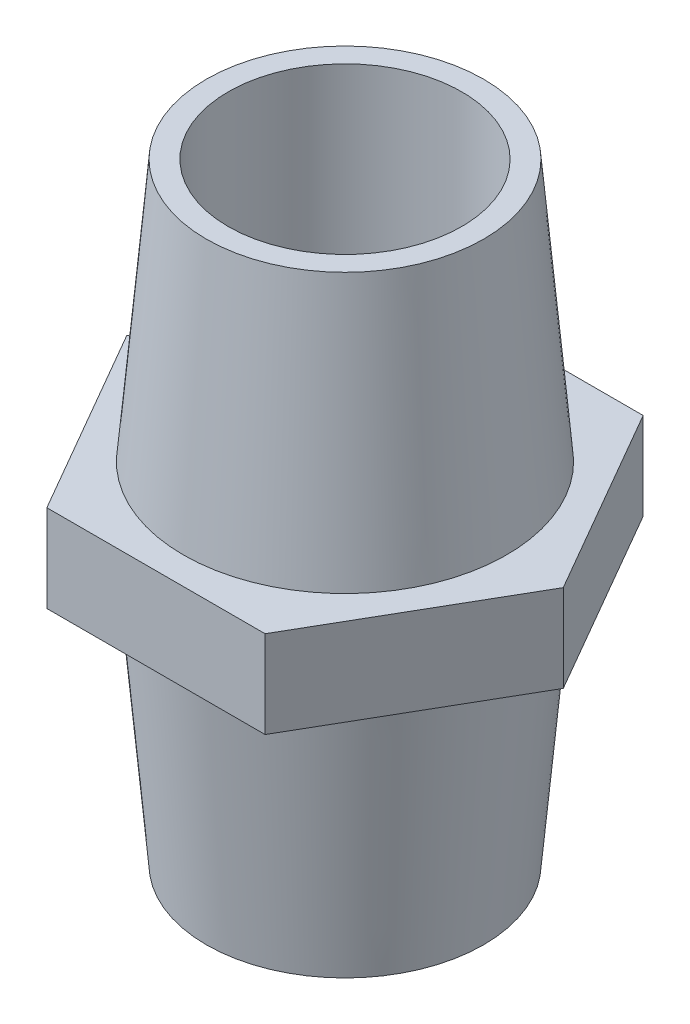
from build123d import *

# Parameters (mm, degrees)
CROQUIS2_OUTSIDE_W    = 43.94
CROQUIS2_OUTSIDE_H    = 43.94
CORTAR_EXTRUIR1_DEPTH = 25


with BuildPart() as part:
    # Croquis1 → Revolución1 (revolve)
    with BuildSketch(Plane.XY):
        Polygon((8.025, 24), (8.025, -18), (9.525, -18), (11.11, 0), (15, 0), (15, 6), (11.11, 6), (9.525, 24), align=None)
    revolve(axis=Axis((0, 30.334405112, 0), (0, -1, 0)))

    # Croquis2 outside → Cortar-Extruir1 (cut, through all)
    with BuildSketch(Plane(origin=(0, 6, 0), x_dir=(1, 0, 0), z_dir=(0, 1, 0))):
        Rectangle(CROQUIS2_OUTSIDE_W, CROQUIS2_OUTSIDE_H)
        Polygon((15, 0), (7.5, 12.990381057), (-7.5, 12.990381057), (-15, 0), (-7.5, -12.990381057), (7.5, -12.990381057), align=None, mode=Mode.SUBTRACT)
    extrude(amount=-CORTAR_EXTRUIR1_DEPTH, mode=Mode.SUBTRACT)


solid = part.part
